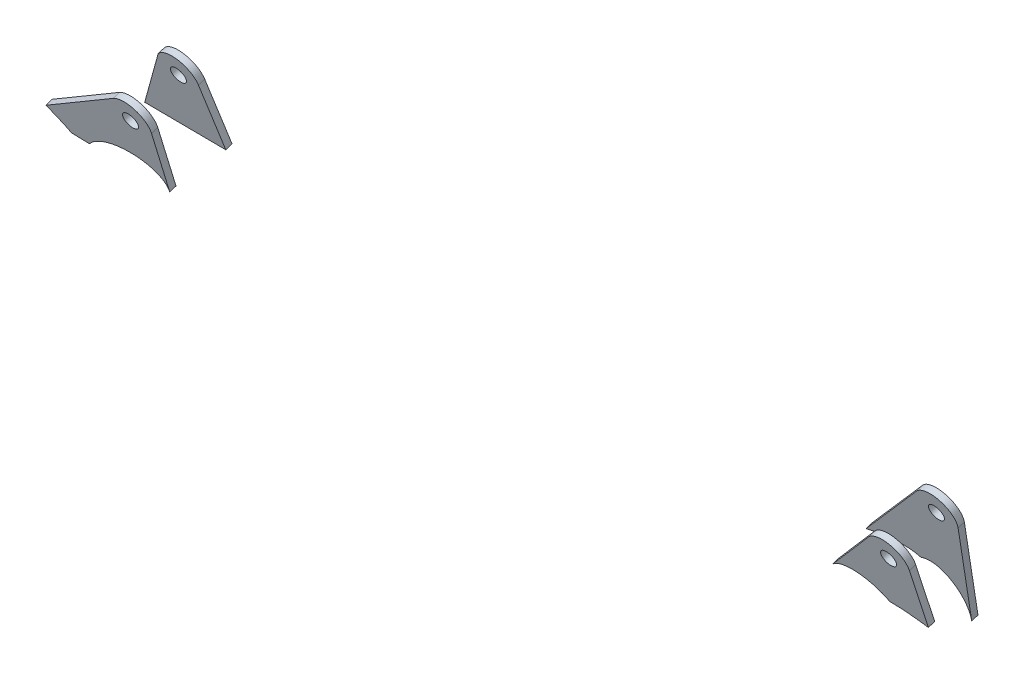
from build123d import *

# Parameters (mm, degrees)
SZKIC1_R                      = 3.5
DODANIE_WYCI_GNI_CIE1_DEPTH   = 3
DODANIE_WYCI_GNI_CIE1_2_DEPTH = 3
SZKIC2_R                      = 3.5
DODANIE_WYCI_GNI_CIE2_DEPTH   = 3
DODANIE_WYCI_GNI_CIE2_2_DEPTH = 3


with BuildPart() as part:
    # Szkic1 → Dodanie-wyciągnięcie1 (new body)
    with BuildSketch(Plane(origin=(0, -45.881759644, 139.410201522), x_dir=(-1, 0, 0), z_dir=(0, 0.312617861, -0.949878978))):
        with BuildLine():
            Line((-1507.324679486, 391.926038808), (-1497.047683756, 339.176346736))
            add(Edge.make_bspline(
                [(-1497.047683756, 339.176346736), (-1500.295889417, 355.848714116), (-1491.071283731, 366.144487415), (-1480.574167069, 360.502687303)],
                knots=[0.562260196, 0.562260196, 0.562260196, 0.562260196, 1, 1, 1, 1], degree=3, weights=[0.855160957, 0.563995223, 0.612274904, 1]))
            add(Edge.make_bspline(
                [(-1480.574167069, 360.502687303), (-1475.881961605, 362.950113366), (-1466.864587333, 362.760048919), (-1454.859781154, 358.631833208)],
                knots=[0.566884898, 0.566884898, 0.566884898, 0.566884898, 0.725491645, 0.725491645, 0.725491645, 0.725491645], degree=3, weights=[0.768249126, 0.613351575, 0.525536958, 0.504805276]))
            Line((-1454.859781154, 358.631833208), (-1490.832934288, 399.978363049))
            ThreePointArc((-1490.832934288, 399.978363049), (-1502.168189741, 402.279481514), (-1507.324679486, 391.926038808))
        make_face()
        with Locations((-1497.999999998, 393.742726025)):
            Circle(SZKIC1_R, mode=Mode.SUBTRACT)
    extrude(amount=DODANIE_WYCI_GNI_CIE1_DEPTH)


with BuildPart() as body_2:
    # Szkic1 → Dodanie-wyci_gni_cie1 2 (new body)
    with BuildSketch(Plane(origin=(0, -45.881759644, 139.410201522), x_dir=(-1, 0, 0), z_dir=(0, 0.312617861, -0.949878978))):
        with BuildLine():
            Line((-1161.454019497, 394.676275891), (-1164.450401157, 364.332047192))
            add(Edge.make_bspline(
                [(-1164.450401157, 364.332047192), (-1152.611051852, 364.492579355), (-1140.312798139, 364.64531969), (-1127.578994798, 364.790268273)],
                knots=[0.951482823, 0.951482823, 0.951482823, 0.951482823, 1, 1, 1, 1], degree=3, weights=[0.978494801, 0.985297676, 0.992466075, 1]))
            Line((-1127.578994798, 364.790268273), (-1144.654879263, 399.767607879))
            ThreePointArc((-1144.654879263, 399.767607879), (-1154.755409017, 402.834355205), (-1161.454019497, 394.676275891))
        make_face()
        with Locations((-1152, 393.742726025)):
            Circle(SZKIC1_R, mode=Mode.SUBTRACT)
    extrude(amount=DODANIE_WYCI_GNI_CIE1_2_DEPTH)


with BuildPart() as body_3:
    # Szkic2 → Dodanie-wyciągnięcie2 (new body)
    with BuildSketch(Plane(origin=(0, -53.071970442, 161.257418019), x_dir=(-1, 0, 0), z_dir=(0, 0.312617861, -0.949878978))):
        with BuildLine():
            Line((-1146.464512352, 401.463372144), (-1106.988460457, 373.160145407))
            add(Edge.make_bspline(
                [(-1116.21528424, 365.135364776), (-1114.294169782, 367.270410001), (-1111.261896249, 369.936504078), (-1106.988460457, 373.160145407)],
                knots=[0.553642055, 0.553642055, 0.553642055, 0.553642055, 0.604482392, 0.604482392, 0.604482392, 0.604482392], degree=3, weights=[0.815243898, 0.763889723, 0.719183774, 0.681126049]))
            Line((-1116.21528424, 365.135364776), (-1124.308276373, 364.867875963))
            add(Edge.make_bspline(
                [(-1160.511269619, 363.671298048), (-1160.5381986, 364.486046247), (-1160.446549462, 365.259098088), (-1160.25609924, 365.985762148), (-1157.225619941, 377.548575622), (-1137.029655801, 380.912629744), (-1124.308276373, 364.867875963)],
                knots=[0.957482723, 0.957482723, 0.957482723, 0.957482723, 1, 1, 1, 1.36661687, 1.36661687, 1.36661687, 1.36661687], degree=3, weights=[0.844392641, 0.891441177, 0.943310297, 1, 0.511177507, 0.380776158, 0.608795955]))
            Line((-1160.511269619, 363.671298048), (-1161.494815212, 393.428904288))
            ThreePointArc((-1161.494815212, 393.428904288), (-1156.478530687, 402.120838156), (-1146.464512352, 401.463372144))
        make_face()
        with Locations((-1152, 393.742726025)):
            Circle(SZKIC2_R, mode=Mode.SUBTRACT)
    extrude(amount=DODANIE_WYCI_GNI_CIE2_DEPTH)


with BuildPart() as body_4:
    # Szkic2 → Dodanie-wyci_gni_cie2 2 (new body)
    with BuildSketch(Plane(origin=(0, -53.071970442, 161.257418019), x_dir=(-1, 0, 0), z_dir=(0, 0.312617861, -0.949878978))):
        with BuildLine():
            Line((-1490.818309173, 399.961513437), (-1464.75604489, 369.863825275))
            add(Edge.make_bspline(
                [(-1490.288359321, 367.537665914), (-1482.924639067, 375.68919221), (-1471.160621906, 377.260072958), (-1464.75604489, 369.863825275)],
                knots=[0, 0, 0, 0, 0.854312736, 0.854312736, 0.854312736, 0.854312736], degree=3, weights=[1, 0.699634369, 0.655874922, 0.868721659]))
            add(Edge.make_bspline(
                [(-1507.271943481, 365.248099091), (-1501.112829495, 366.729517203), (-1495.333465921, 367.467322117), (-1490.288359321, 367.537665914)],
                knots=[0.829977, 0.829977, 0.829977, 0.829977, 0.944345935, 0.944345935, 0.944345935, 0.944345935], degree=3, weights=[0.725470626, 0.755309292, 0.806482945, 0.878991584]))
            Line((-1507.271943481, 365.248099091), (-1507.499694933, 393.666593585))
            ThreePointArc((-1507.499694933, 393.666593585), (-1501.354070622, 402.630932269), (-1490.818309173, 399.961513437))
        make_face()
        with Locations((-1497.999999998, 393.742726025)):
            Circle(SZKIC2_R, mode=Mode.SUBTRACT)
    extrude(amount=DODANIE_WYCI_GNI_CIE2_2_DEPTH)


solid = Compound([part.part, body_2.part, body_3.part, body_4.part])
